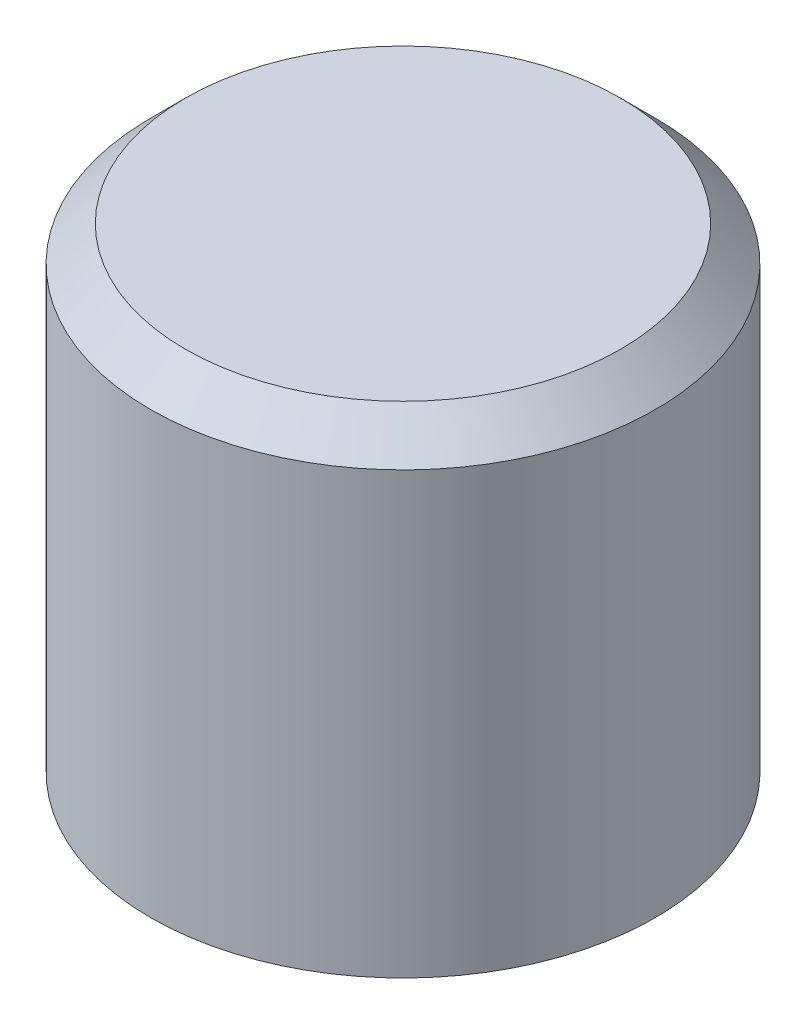
from build123d import *

# Parameters (mm, degrees)
SKETCH1_R           = 3.625
BOSS_EXTRUDE1_DEPTH = 6.82
CHAMFER1_SIZE       = 0.5
SKETCH2_W           = 3.2
SKETCH2_H           = 3.2
CUT_EXTRUDE1_DEPTH  = 2.93


with BuildPart() as part:
    # Sketch1 → Boss-Extrude1 (new body)
    with BuildSketch(Plane(origin=(0, 0, 0), x_dir=(1, 0, 0), z_dir=(0, 1, 0))):
        Circle(SKETCH1_R)
    extrude(amount=BOSS_EXTRUDE1_DEPTH)

    # Chamfer1
    chamfer1_edges = [part.edges().sort_by_distance(p)[0] for p in [
        (-3.625, 6.82, 0),
    ]]
    chamfer(chamfer1_edges, length=CHAMFER1_SIZE)

    # Sketch2 → Cut-Extrude1 (cut)
    with BuildSketch(Plane.XZ):
        Rectangle(SKETCH2_W, SKETCH2_H)
    extrude(amount=-CUT_EXTRUDE1_DEPTH, mode=Mode.SUBTRACT)


solid = part.part
